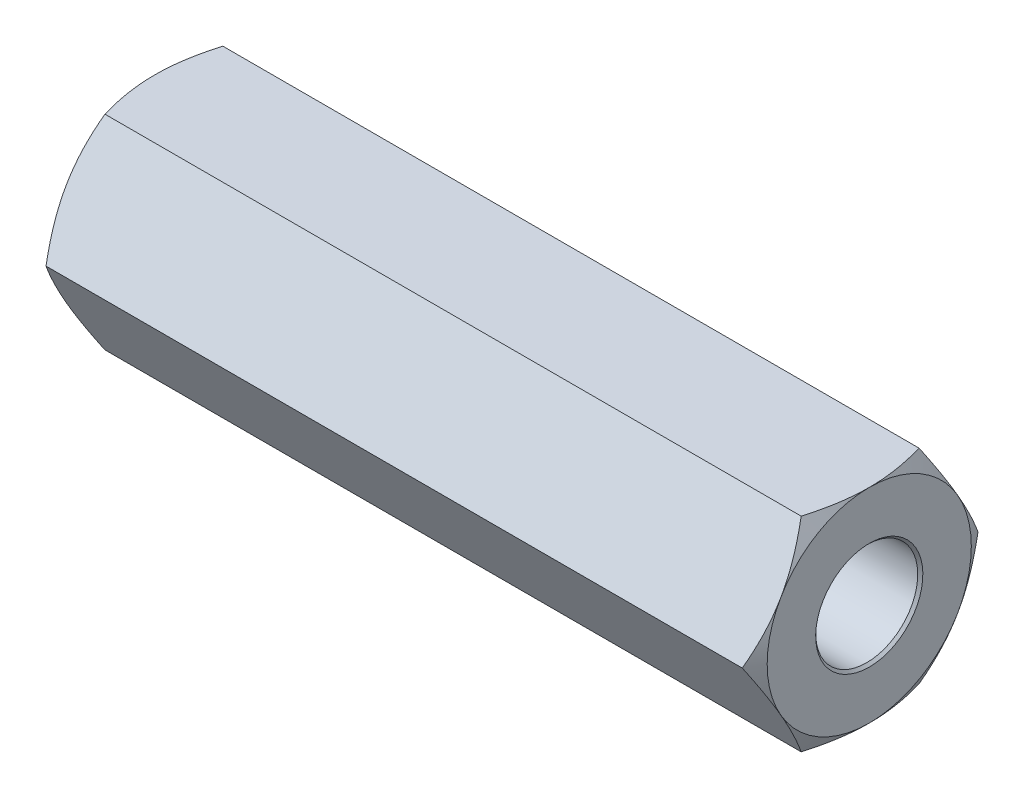
from build123d import *

# Parameters (mm, degrees)
BOSS_EXTRUDE1_DEPTH = 28
SKETCH4_OUTSIDE_W   = 117.808
SKETCH4_OUTSIDE_H   = 116.57
SKETCH4_OUTSIDE_R   = 4
CUT_EXTRUDE1_DEPTH  = 29
CUT_EXTRUDE1_TAPER  = 60
SKETCH5_OUTSIDE_W   = 117.808
SKETCH5_OUTSIDE_H   = 116.57
SKETCH5_OUTSIDE_R   = 4
CUT_EXTRUDE2_DEPTH  = 29
CUT_EXTRUDE2_TAPER  = 60


with BuildPart() as part:
    # Sketch2 → Boss-Extrude1 (new body)
    with BuildSketch(Plane(origin=(0, 0, 0), x_dir=(0, 0, -1), z_dir=(1, 0, 0))):
        Polygon((2.309401077, 4), (-2.309401077, 4), (-4.618802154, 0), (-2.309401077, -4), (2.309401077, -4), (4.618802154, 0), align=None)
    extrude(amount=BOSS_EXTRUDE1_DEPTH)

    # Sketch3 → Cut-Revolve1 (revolve, cut)
    with BuildSketch(Plane.XY):
        Polygon((0, 2.1), (0.1, 2), (11.1, 2), (11.1, 0), (0, 0), align=None)
        Polygon((28, 0), (16.9, 0), (16.9, 2), (27.9, 2), (28, 2.1), align=None)
    revolve(axis=Axis((0, 0, 0), (1, 0, 0)), mode=Mode.SUBTRACT)

    # Sketch4 outside → Cut-Extrude1 (cut, through all)
    with BuildSketch(Plane.ZY):
        Rectangle(SKETCH4_OUTSIDE_W, SKETCH4_OUTSIDE_H)
        Circle(SKETCH4_OUTSIDE_R, mode=Mode.SUBTRACT)
    extrude(amount=-CUT_EXTRUDE1_DEPTH, taper=CUT_EXTRUDE1_TAPER, mode=Mode.SUBTRACT)

    # Sketch5 outside → Cut-Extrude2 (cut, through all)
    with BuildSketch(Plane(origin=(28, 0, 0), x_dir=(0, 0, -1), z_dir=(1, 0, 0))):
        Rectangle(SKETCH5_OUTSIDE_W, SKETCH5_OUTSIDE_H)
        Circle(SKETCH5_OUTSIDE_R, mode=Mode.SUBTRACT)
    extrude(amount=-CUT_EXTRUDE2_DEPTH, taper=CUT_EXTRUDE2_TAPER, mode=Mode.SUBTRACT)


solid = part.part
